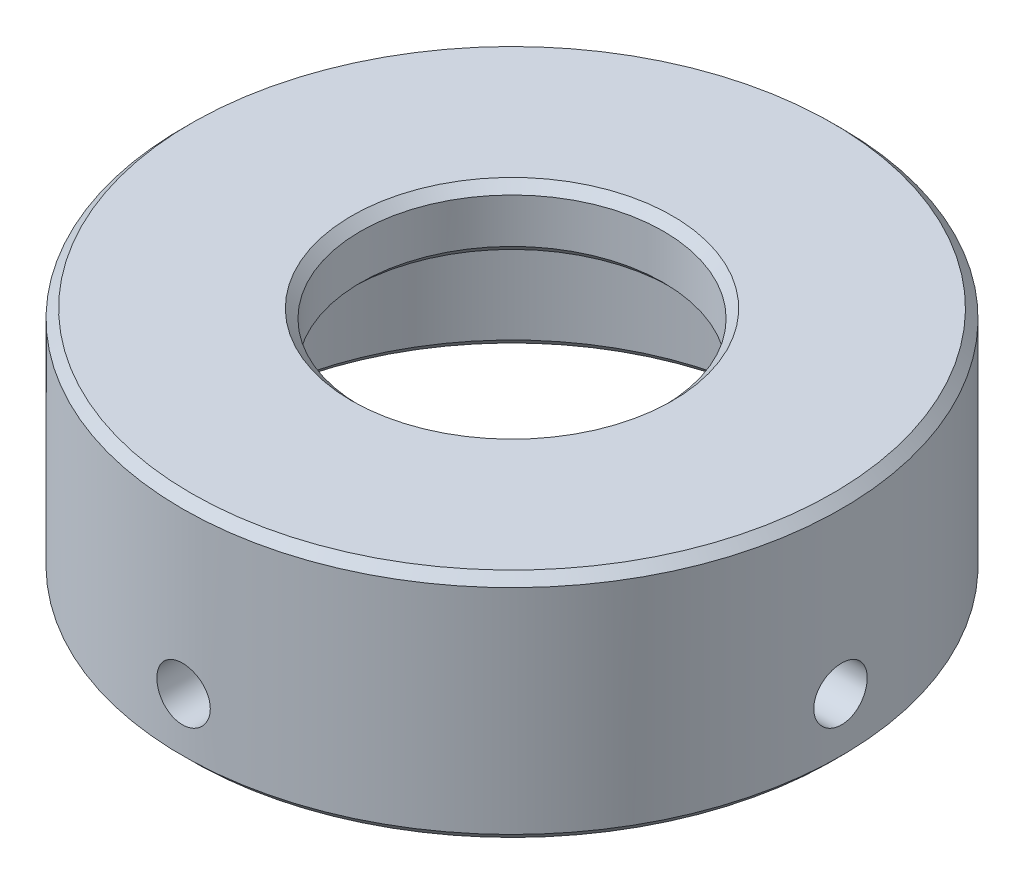
from build123d import *

# Parameters (mm, degrees)
CHAMFER1_SIZE                          = 0.5
F_3_0_3_DIAMETER_HOLE1_D               = 3
F_3_0_3_DIAMETER_HOLE1_DEPTH           = 12
F_3_0_3_DIAMETER_HOLE1_TIP             = 0.901290929
F_3_0_3_DIAMETER_HOLE1_ON_FACE_2_D     = 3
F_3_0_3_DIAMETER_HOLE1_ON_FACE_2_DEPTH = 12
F_3_0_3_DIAMETER_HOLE1_ON_FACE_2_TIP   = 0.901290929
F_3_0_3_DIAMETER_HOLE1_ON_FACE_3_D     = 3
F_3_0_3_DIAMETER_HOLE1_ON_FACE_3_DEPTH = 12
F_3_0_3_DIAMETER_HOLE1_ON_FACE_3_TIP   = 0.901290929


with BuildPart() as part:
    # Sketch2 → Revolve1 (revolve)
    with BuildSketch(Plane.XY, mode=Mode.PRIVATE) as revolve1_sk:
        Polygon((15.5, 0), (15.5, -9.5), (18.5, -9.5), (18.5, 3.5), (8.5, 3.5), (8.5, 0), align=None)
    revolve(revolve1_sk.sketch.rotate(Axis((0, 0, 0), (0, 1, 0)), 90), axis=Axis((0, 0, 0), (0, 1, 0)))  # turned: the seam where the file's is

    # Chamfer1
    chamfer1_edges = [part.edges().sort_by_distance(p)[0] for p in [
        (0, 0, 8.5),
        (0, 0, 15.5),
        (0, -9.5, 15.5),
        (0, -9.5, 18.5),
        (0, 3.5, 18.5),
        (0, 3.5, 8.5),
    ]]
    chamfer(chamfer1_edges, length=CHAMFER1_SIZE)

    # Ø3.0 (3) Diameter Hole1
    with Locations(Plane(origin=(-18.5, -6, 0), x_dir=(0, 0, -1), z_dir=(-1, 0, 0))):
        with Locations((0, 0)):
            Hole(F_3_0_3_DIAMETER_HOLE1_D / 2, depth=F_3_0_3_DIAMETER_HOLE1_DEPTH)
            with Locations((0, 0, -(F_3_0_3_DIAMETER_HOLE1_DEPTH + F_3_0_3_DIAMETER_HOLE1_TIP / 2))):  # 118° drill point
                Cone(0, F_3_0_3_DIAMETER_HOLE1_D / 2, F_3_0_3_DIAMETER_HOLE1_TIP, mode=Mode.SUBTRACT)

    # Ø3.0 (3) Diameter Hole1 on face 2
    with Locations(Plane(origin=(0, -6, 18.5), x_dir=(1, 0, 0), z_dir=(0, 0, 1))):
        with Locations((0, 0)):
            Hole(F_3_0_3_DIAMETER_HOLE1_ON_FACE_2_D / 2, depth=F_3_0_3_DIAMETER_HOLE1_ON_FACE_2_DEPTH)
            with Locations((0, 0, -(F_3_0_3_DIAMETER_HOLE1_ON_FACE_2_DEPTH + F_3_0_3_DIAMETER_HOLE1_ON_FACE_2_TIP / 2))):  # 118° drill point
                Cone(0, F_3_0_3_DIAMETER_HOLE1_ON_FACE_2_D / 2, F_3_0_3_DIAMETER_HOLE1_ON_FACE_2_TIP, mode=Mode.SUBTRACT)

    # Ø3.0 (3) Diameter Hole1 on face 3
    with Locations(Plane(origin=(18.5, -6, 0), x_dir=(0, 0, 1), z_dir=(1, 0, 0))):
        with Locations((0, 0)):
            Hole(F_3_0_3_DIAMETER_HOLE1_ON_FACE_3_D / 2, depth=F_3_0_3_DIAMETER_HOLE1_ON_FACE_3_DEPTH)
            with Locations((0, 0, -(F_3_0_3_DIAMETER_HOLE1_ON_FACE_3_DEPTH + F_3_0_3_DIAMETER_HOLE1_ON_FACE_3_TIP / 2))):  # 118° drill point
                Cone(0, F_3_0_3_DIAMETER_HOLE1_ON_FACE_3_D / 2, F_3_0_3_DIAMETER_HOLE1_ON_FACE_3_TIP, mode=Mode.SUBTRACT)


solid = part.part
